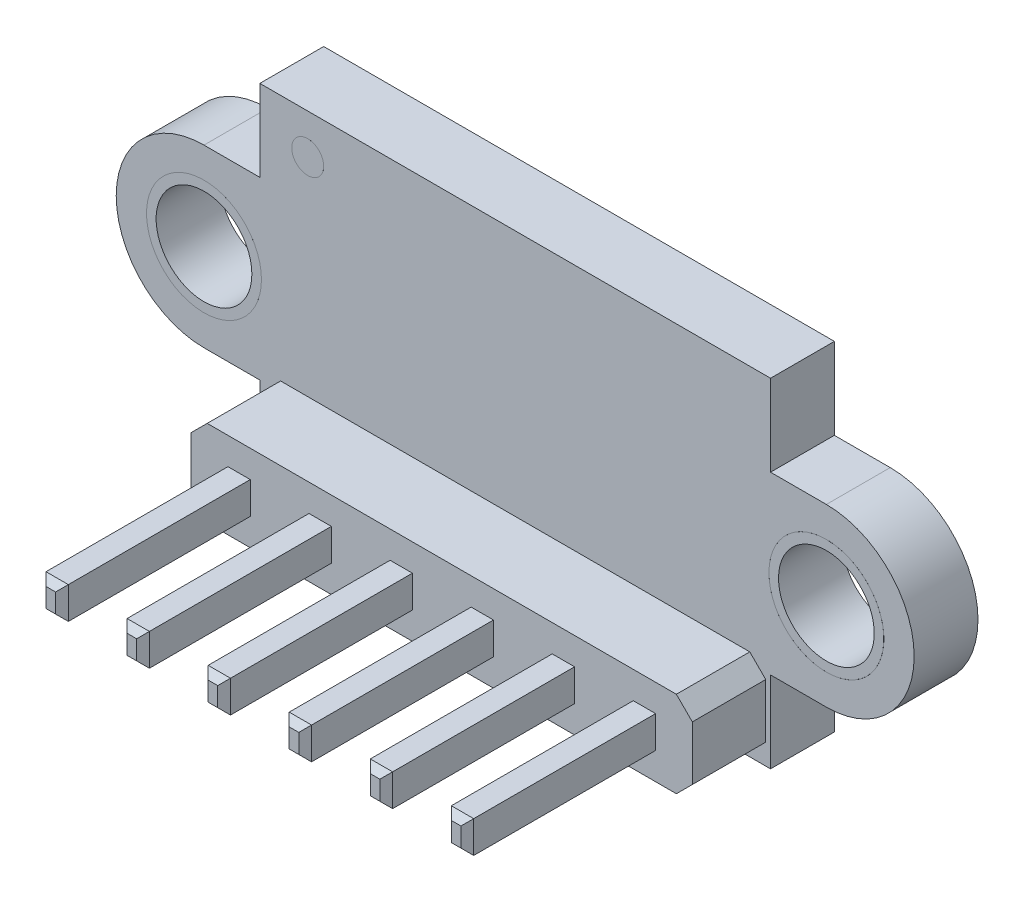
from build123d import *

# Parameters (mm, degrees)
SKETCH1_W                = 16
SKETCH1_H                = 10.6
BOSS_EXTRUDE1_DEPTH      = 1
SKETCH2_R                = 1.5
BOSS_EXTRUDE2_DEPTH      = 1
SKETCH9_R                = 1.8
SKETCH9_R_2              = 1.5
SKETCH9_R_3              = 0.5
BOSS_EXTRUDE9_DEPTH      = 0.0001
SKETCH3_W                = 15.7
SKETCH3_H                = 2.7
BOSS_EXTRUDE3_DEPTH      = 2.3
CHAMFER1_SIZE            = 0.5
SKETCH4_W                = 0.7
SKETCH4_H                = 1
BOSS_EXTRUDE4_DEPTH      = 5.9
BOSS_EXTRUDE4_DEPTH_BACK = 6
CHAMFER3_SIZE            = 0.4
CHAMFER2_SIZE            = 0.2
SKETCH6_W                = 4.4
SKETCH6_H                = 2.4
BOSS_EXTRUDE6_DEPTH      = 1.2
SKETCH8_R                = 0.15
SKETCH8_R_2              = 0.05
CUT_EXTRUDE1_DEPTH       = 0.01
SKETCH5_W                = 4.8
SKETCH5_H                = 2.8
SKETCH5_W_2              = 4.6
SKETCH5_H_2              = 2.6
INSCRI_ES_DEPTH          = 0.0001


with BuildPart() as part:
    # Sketch1 → Boss-Extrude1 (new body, symmetric)
    with BuildSketch(Plane.XY):
        Rectangle(SKETCH1_W, SKETCH1_H)
    extrude(amount=BOSS_EXTRUDE1_DEPTH, both=True)

    # Sketch2 → Boss-Extrude2 (add, symmetric)
    with BuildSketch(Plane.XY):
        with BuildLine():
            Line((-9.75, 2.75), (-8, 2.75))
            Line((-8, 2.75), (-8, -2.75))
            Line((-8, -2.75), (-9.75, -2.75))
            ThreePointArc((-9.75, -2.75), (-12.5, 0), (-9.75, 2.75))
        make_face()
        with Locations((-9.75, 0)):
            Circle(SKETCH2_R, mode=Mode.SUBTRACT)
        with BuildLine():
            Line((9.75, -2.75), (8, -2.75))
            Line((8, -2.75), (8, 2.75))
            Line((8, 2.75), (9.75, 2.75))
            ThreePointArc((9.75, 2.75), (12.5, 0), (9.75, -2.75))
        make_face()
        with Locations((9.75, 0)):
            Circle(SKETCH2_R, mode=Mode.SUBTRACT)
    extrude(amount=BOSS_EXTRUDE2_DEPTH, both=True)

    # Sketch9 → Boss-Extrude9 (add)
    with BuildSketch(Plane(origin=(0, 0, -1), x_dir=(-1, 0, 0), z_dir=(0, 0, -1))):
        with Locations((-9.75, 0)):
            Circle(SKETCH9_R)
        with Locations((-9.75, 0)):
            Circle(SKETCH9_R_2, mode=Mode.SUBTRACT)
        with Locations((9.75, 0)):
            Circle(SKETCH9_R)
        with Locations((9.75, 0)):
            Circle(SKETCH9_R_2, mode=Mode.SUBTRACT)
        with Locations((6.5, 4.05)):
            Circle(SKETCH9_R_3)
    boss_extrude9 = extrude(amount=BOSS_EXTRUDE9_DEPTH)

    # Mirror4: Boss-Extrude9 across plane
    add(boss_extrude9.mirror(Plane.XY))

    # Sketch3 → Boss-Extrude3 (add)
    with BuildSketch(Plane.XY.offset(1)):
        with Locations((0, -3.8)):
            Rectangle(SKETCH3_W, SKETCH3_H)
    extrude(amount=BOSS_EXTRUDE3_DEPTH)

    # Chamfer1
    chamfer1_edges = [part.edges().sort_by_distance(p)[0] for p in [
        (-7.85, -2.45, 2.15),
        (-7.85, -5.15, 2.15),
        (7.85, -5.15, 2.15),
        (7.85, -2.45, 2.15),
    ]]
    chamfer(chamfer1_edges, length=CHAMFER1_SIZE)

    # Sketch4 → Boss-Extrude4 (add, two sides)
    with BuildSketch(Plane.XY.offset(3.3)) as boss_extrude4_sk:
        with Locations((-3.81, -3.8)):
            Rectangle(SKETCH4_W, SKETCH4_H)
        with Locations((-6.35, -3.8)):
            Rectangle(SKETCH4_W, SKETCH4_H)
        with Locations((-1.27, -3.8)):
            Rectangle(SKETCH4_W, SKETCH4_H)
        with Locations((1.27, -3.8)):
            Rectangle(SKETCH4_W, SKETCH4_H)
        with Locations((3.81, -3.8)):
            Rectangle(SKETCH4_W, SKETCH4_H)
        with Locations((6.35, -3.8)):
            Rectangle(SKETCH4_W, SKETCH4_H)
    extrude(amount=BOSS_EXTRUDE4_DEPTH)
    extrude(boss_extrude4_sk.sketch, amount=-BOSS_EXTRUDE4_DEPTH_BACK)

    # Chamfer3
    chamfer3_edges = [part.edges().sort_by_distance(p)[0] for p in [
        (-6.7, -3.8, -1),
        (-6.35, -3.3, -1),
        (-6, -3.8, -1),
        (-6.35, -4.3, -1),
        (-4.16, -3.8, -1),
        (-3.81, -3.3, -1),
        (-3.46, -3.8, -1),
        (-3.81, -4.3, -1),
        (-1.62, -3.8, -1),
        (-1.27, -3.3, -1),
        (-0.92, -3.8, -1),
        (-1.27, -4.3, -1),
        (0.92, -3.8, -1),
        (1.27, -3.3, -1),
        (1.62, -3.8, -1),
        (1.27, -4.3, -1),
        (3.46, -3.8, -1),
        (3.81, -3.3, -1),
        (4.16, -3.8, -1),
        (3.81, -4.3, -1),
        (6, -3.8, -1),
        (6.35, -3.3, -1),
        (6.7, -3.8, -1),
        (6.35, -4.3, -1),
    ]]
    chamfer(chamfer3_edges, length=CHAMFER3_SIZE)

    # Chamfer2
    chamfer2_edges = [part.edges().sort_by_distance(p)[0] for p in [
        (-6.7, -3.8, -2.7),
        (-6.35, -3.3, -2.7),
        (-6, -3.8, -2.7),
        (-6.35, -4.3, -2.7),
        (-6.7, -3.8, 9.2),
        (-6.35, -4.3, 9.2),
        (-6, -3.8, 9.2),
        (-6.35, -3.3, 9.2),
        (-4.16, -3.8, -2.7),
        (-3.81, -3.3, -2.7),
        (-3.46, -3.8, -2.7),
        (-3.81, -4.3, -2.7),
        (-4.16, -3.8, 9.2),
        (-3.81, -4.3, 9.2),
        (-3.46, -3.8, 9.2),
        (-3.81, -3.3, 9.2),
        (-1.62, -3.8, -2.7),
        (-1.27, -3.3, -2.7),
        (-0.92, -3.8, -2.7),
        (-1.27, -4.3, -2.7),
        (-1.62, -3.8, 9.2),
        (-1.27, -4.3, 9.2),
        (-0.92, -3.8, 9.2),
        (-1.27, -3.3, 9.2),
        (0.92, -3.8, -2.7),
        (1.27, -3.3, -2.7),
        (1.62, -3.8, -2.7),
        (1.27, -4.3, -2.7),
        (0.92, -3.8, 9.2),
        (1.27, -4.3, 9.2),
        (1.62, -3.8, 9.2),
        (1.27, -3.3, 9.2),
        (3.46, -3.8, -2.7),
        (3.81, -3.3, -2.7),
        (4.16, -3.8, -2.7),
        (3.81, -4.3, -2.7),
        (3.46, -3.8, 9.2),
        (3.81, -4.3, 9.2),
        (4.16, -3.8, 9.2),
        (3.81, -3.3, 9.2),
        (6, -3.8, -2.7),
        (6.35, -3.3, -2.7),
        (6.7, -3.8, -2.7),
        (6.35, -4.3, -2.7),
        (6, -3.8, 9.2),
        (6.35, -4.3, 9.2),
        (6.7, -3.8, 9.2),
        (6.35, -3.3, 9.2),
    ]]
    chamfer(chamfer2_edges, length=CHAMFER2_SIZE)

    # Sketch6 → Boss-Extrude6 (add)
    with BuildSketch(Plane(origin=(0, 0, -1), x_dir=(-1, 0, 0), z_dir=(0, 0, -1))):
        with Locations((0, 2.1)):
            Rectangle(SKETCH6_W, SKETCH6_H)
    extrude(amount=BOSS_EXTRUDE6_DEPTH)

    # Sketch8 → Cut-Extrude1 (cut)
    with BuildSketch(Plane(origin=(0, 0, -2.2), x_dir=(-1, 0, 0), z_dir=(0, 0, -1))):
        with Locations((-1.55, 2.1)):
            Circle(SKETCH8_R)
        with Locations((1.65, 2.1)):
            Circle(SKETCH8_R_2)
    extrude(amount=-CUT_EXTRUDE1_DEPTH, mode=Mode.SUBTRACT)

    # Sketch5 → Inscrições (add)
    with BuildSketch(Plane(origin=(0, 0, -1), x_dir=(-1, 0, 0), z_dir=(0, 0, -1))):
        with Locations((0, 2.1)):
            Rectangle(SKETCH5_W, SKETCH5_H)
        with Locations((0, 2.1)):
            Rectangle(SKETCH5_W_2, SKETCH5_H_2, mode=Mode.SUBTRACT)
        Polygon((-3.145569905, 4.655439852), (-3.07345452, 4.655439852), (-2.82345452, 4.064394179), (-2.57345452, 4.655439852), (-2.501339136, 4.655439852), (-2.818646828, 3.905439852), (-2.828262213, 3.905439852), align=None)
        Polygon((-2.366723751, 4.655439852), (-2.299416059, 4.655439852), (-2.299416059, 3.982362929), (-2.01095452, 3.982362929), (-2.01095452, 3.905439852), (-2.366723751, 3.905439852), align=None)
        with BuildLine():
            Line((-1.482108366, 4.655439852), (-1.482108366, 4.578516775))
            Line((-1.482108366, 4.578516775), (-1.73721654, 4.578516775))
            Line((-1.73721654, 4.578516775), (-1.777631203, 4.38125115))
            add(Edge.make_bspline(
                [(-1.777631203, 4.38125115), (-1.769690658, 4.383443351), (-1.754307109, 4.387690394), (-1.731601425, 4.392405916), (-1.710045953, 4.395248511), (-1.696058373, 4.395636649), (-1.689289857, 4.395824467)],
                knots=[0, 0, 0, 0, 2.4708e-05, 4.7867e-05, 6.9521e-05, 8.9823e-05, 8.9823e-05, 8.9823e-05, 8.9823e-05], degree=3))
            add(Edge.make_bspline(
                [(-1.689289857, 4.395824467), (-1.68091477, 4.395643195), (-1.664447256, 4.395286769), (-1.640353196, 4.39186423), (-1.61735329, 4.386477106), (-1.59549564, 4.37895128), (-1.574739807, 4.369327765), (-1.555276758, 4.35730635), (-1.536814348, 4.343263493), (-1.519683793, 4.327118133), (-1.504142869, 4.309349215), (-1.490478729, 4.290243957), (-1.478872459, 4.26998803), (-1.469538012, 4.248387899), (-1.462084226, 4.225682366), (-1.457123084, 4.201632527), (-1.453819504, 4.176465073), (-1.453450421, 4.159256951), (-1.453262213, 4.150481919)],
                knots=[0, 0, 0, 0, 2.5112e-05, 4.9377e-05, 7.2845e-05, 9.5889e-05, 0.000118607, 0.000141333, 0.000164381, 0.000188083, 0.000211827, 0.000235091, 0.000258441, 0.00028172, 0.000305571, 0.000329999, 0.000355287, 0.0003816, 0.0003816, 0.0003816, 0.0003816], degree=3))
            add(Edge.make_bspline(
                [(-1.453262213, 4.150481919), (-1.453404729, 4.144370015), (-1.453687835, 4.132228803), (-1.455127532, 4.114197903), (-1.457899472, 4.096548725), (-1.461621127, 4.079278926), (-1.466451645, 4.062421204), (-1.472299299, 4.045927305), (-1.479455591, 4.029899889), (-1.487305171, 4.014187304), (-1.496143702, 3.999144767), (-1.505953382, 3.985077127), (-1.516317416, 3.971773353), (-1.527469142, 3.959376124), (-1.539512212, 3.947966906), (-1.552300776, 3.937477989), (-1.565732788, 3.927731989), (-1.580016054, 3.919124519), (-1.5948323, 3.911203885), (-1.61039549, 3.904705985), (-1.626351354, 3.898896586), (-1.642929542, 3.894265973), (-1.660092501, 3.890637568), (-1.677868525, 3.888173154), (-1.696164383, 3.886378203), (-1.708566171, 3.886265841), (-1.714830722, 3.886209083)],
                knots=[0, 0, 0, 0, 1.8339e-05, 3.6431e-05, 5.4215e-05, 7.1897e-05, 8.9397e-05, 0.00010679, 0.000124348, 0.000142019, 0.000159463, 0.000176633, 0.000193434, 0.000210029, 0.000226607, 0.00024315, 0.00025962, 0.000276343, 0.000293143, 0.000309971, 0.000326889, 0.000344059, 0.000361562, 0.000379473, 0.000397877, 0.000416662, 0.000416662, 0.000416662, 0.000416662], degree=3))
            add(Edge.make_bspline(
                [(-1.714830722, 3.886209083), (-1.722303761, 3.886357119), (-1.737006082, 3.886648364), (-1.758546203, 3.889695182), (-1.779270762, 3.894058879), (-1.799012926, 3.900623794), (-1.817949626, 3.908849643), (-1.835825922, 3.919245965), (-1.853098589, 3.931027202), (-1.869065454, 3.944930134), (-1.883884621, 3.960126352), (-1.897150301, 3.976617275), (-1.908964639, 3.994130727), (-1.919138442, 4.01275176), (-1.927816589, 4.032431445), (-1.934634087, 4.053243517), (-1.940136592, 4.075079232), (-1.942464467, 4.090112127), (-1.943646828, 4.097747544)],
                knots=[0, 0, 0, 0, 2.2404e-05, 4.4077e-05, 6.5148e-05, 8.5862e-05, 0.00010638, 0.000126972, 0.00014781, 0.000169011, 0.000190366, 0.000211414, 0.000232415, 0.000253662, 0.000274988, 0.000296843, 0.000319289, 0.000342457, 0.000342457, 0.000342457, 0.000342457], degree=3))
            Line((-1.943646828, 4.097747544), (-1.876339136, 4.097747544))
            add(Edge.make_bspline(
                [(-1.876339136, 4.097747544), (-1.874683016, 4.090595447), (-1.871499863, 4.07684872), (-1.864512917, 4.057534861), (-1.855970229, 4.040323599), (-1.845812154, 4.024987259), (-1.833694291, 4.011613903), (-1.819866556, 3.999695961), (-1.804363472, 3.988944148), (-1.787136352, 3.979982126), (-1.76896212, 3.972338822), (-1.749940575, 3.967249173), (-1.730589644, 3.96367041), (-1.717501422, 3.963312176), (-1.710924472, 3.96313216)],
                knots=[0, 0, 0, 0, 2.2009e-05, 4.2303e-05, 6.1452e-05, 7.9536e-05, 9.7303e-05, 0.000115408, 0.000134203, 0.000153761, 0.00017357, 0.000193217, 0.00021273, 0.00023244, 0.00023244, 0.00023244, 0.00023244], degree=3))
            add(Edge.make_bspline(
                [(-1.710924472, 3.96313216), (-1.704504806, 3.963308041), (-1.691864429, 3.963654352), (-1.673261989, 3.966319854), (-1.655302088, 3.970425048), (-1.63816194, 3.976568588), (-1.62154161, 3.984035314), (-1.605861516, 3.993617116), (-1.590668043, 4.004644263), (-1.576433443, 4.017277826), (-1.563396418, 4.031199904), (-1.551877249, 4.046087916), (-1.542282196, 4.061970098), (-1.534196316, 4.078571488), (-1.528056323, 4.096074036), (-1.523676113, 4.114395716), (-1.521104029, 4.133581783), (-1.520750204, 4.146668064), (-1.520569905, 4.153336487)],
                knots=[0, 0, 0, 0, 1.9252e-05, 3.7907e-05, 5.6274e-05, 7.4425e-05, 9.2442e-05, 0.000110839, 0.00012944, 0.000148704, 0.000167838, 0.000186589, 0.000205063, 0.000223408, 0.000241893, 0.000260587, 0.000279837, 0.00029984, 0.00029984, 0.00029984, 0.00029984], degree=3))
            add(Edge.make_bspline(
                [(-1.520569905, 4.153336487), (-1.520711008, 4.159352719), (-1.520987196, 4.171128638), (-1.523243747, 4.188357039), (-1.527168812, 4.204658406), (-1.532616787, 4.220111456), (-1.539533824, 4.234730765), (-1.547986605, 4.248531421), (-1.558133762, 4.261331528), (-1.569724881, 4.273137075), (-1.582423033, 4.284032405), (-1.596446692, 4.293320424), (-1.61150239, 4.30113412), (-1.627408733, 4.307877263), (-1.644544069, 4.31272028), (-1.662569061, 4.316356255), (-1.681678356, 4.318459547), (-1.694743503, 4.318751381), (-1.701459328, 4.31890139)],
                knots=[0, 0, 0, 0, 1.8044e-05, 3.532e-05, 5.2009e-05, 6.826e-05, 8.4389e-05, 0.000100442, 0.000116703, 0.000133277, 0.000150013, 0.000166806, 0.000183607, 0.00020085, 0.000218536, 0.000236922, 0.000255969, 0.000276115, 0.000276115, 0.000276115, 0.000276115], degree=3))
            add(Edge.make_bspline(
                [(-1.701459328, 4.31890139), (-1.70727267, 4.318776978), (-1.719275746, 4.318520098), (-1.73768778, 4.316628706), (-1.757036007, 4.313577428), (-1.777246256, 4.309380375), (-1.798379222, 4.303888002), (-1.820390308, 4.297306323), (-1.843325793, 4.289437323), (-1.858779591, 4.283494706), (-1.866723751, 4.280439852)],
                knots=[0, 0, 0, 0, 1.7438e-05, 3.6006e-05, 5.547e-05, 7.6184e-05, 9.7902e-05, 0.000120955, 0.000145091, 0.000170624, 0.000170624, 0.000170624, 0.000170624], degree=3))
            Line((-1.866723751, 4.280439852), (-1.789800674, 4.655439852))
            Line((-1.789800674, 4.655439852), (-1.482108366, 4.655439852))
        make_face()
        with BuildLine():
            Line((-1.28018529, 4.482362929), (-1.347492982, 4.482362929))
            add(Edge.make_bspline(
                [(-1.347492982, 4.482362929), (-1.345669507, 4.489912747), (-1.342104762, 4.504672023), (-1.334669568, 4.525759294), (-1.326569727, 4.545714334), (-1.316843491, 4.564163493), (-1.306234472, 4.581477543), (-1.294079603, 4.597263784), (-1.280939662, 4.611923705), (-1.266405745, 4.624933685), (-1.251163889, 4.636714627), (-1.234999327, 4.646759282), (-1.218237279, 4.655400172), (-1.200761607, 4.662518793), (-1.182520285, 4.667881405), (-1.163678223, 4.671772149), (-1.144186044, 4.674298817), (-1.130954417, 4.674545409), (-1.12423577, 4.674670621)],
                knots=[0, 0, 0, 0, 2.3285e-05, 4.5521e-05, 6.7005e-05, 8.7837e-05, 0.000108014, 0.000127847, 0.000147524, 0.000166988, 0.00018628, 0.000205247, 0.000223994, 0.000242798, 0.000261765, 0.000280947, 0.000300476, 0.000320623, 0.000320623, 0.000320623, 0.000320623], degree=3))
            add(Edge.make_bspline(
                [(-1.12423577, 4.674670621), (-1.114446611, 4.674375072), (-1.095081823, 4.67379042), (-1.066632599, 4.668451612), (-1.03919828, 4.660003369), (-1.013079156, 4.648330428), (-0.988818063, 4.633933147), (-0.967231738, 4.616797846), (-0.948612771, 4.597255138), (-0.932992547, 4.575669589), (-0.92076219, 4.552600551), (-0.911743682, 4.52885766), (-0.906253321, 4.504497238), (-0.905541774, 4.488049249), (-0.90518529, 4.479808842)],
                knots=[0, 0, 0, 0, 2.9343e-05, 5.8047e-05, 8.6512e-05, 0.000115298, 0.000143666, 0.000170931, 0.00019771, 0.000224397, 0.000250609, 0.000275808, 0.000300415, 0.00032512, 0.00032512, 0.00032512, 0.00032512], degree=3))
            add(Edge.make_bspline(
                [(-0.90518529, 4.479808842), (-0.90543463, 4.471878815), (-0.905922552, 4.456360982), (-0.910065489, 4.433706375), (-0.917037545, 4.412354604), (-0.926695351, 4.392215783), (-0.939197112, 4.373417603), (-0.954341262, 4.35591777), (-0.972234689, 4.339638664), (-0.985794462, 4.330313063), (-0.992775434, 4.325511967)],
                knots=[0, 0, 0, 0, 2.3776e-05, 4.6527e-05, 6.881e-05, 9.0985e-05, 0.00011332, 0.000136329, 0.000160261, 0.000185656, 0.000185656, 0.000185656, 0.000185656], degree=3))
            add(Edge.make_bspline(
                [(-0.992775434, 4.325511967), (-0.984797201, 4.321659502), (-0.968990013, 4.314026654), (-0.947443471, 4.299057563), (-0.927883927, 4.28177406), (-0.916975987, 4.268286349), (-0.911495386, 4.261509563)],
                knots=[0, 0, 0, 0, 2.6542e-05, 5.2587e-05, 7.844e-05, 0.000104546, 0.000104546, 0.000104546, 0.000104546], degree=3))
            add(Edge.make_bspline(
                [(-0.911495386, 4.261509563), (-0.907886527, 4.256568617), (-0.900727906, 4.246767635), (-0.89189172, 4.231009829), (-0.883875481, 4.215077367), (-0.877629006, 4.198543209), (-0.872791749, 4.181598991), (-0.869334027, 4.164215621), (-0.867185997, 4.146378902), (-0.866878379, 4.134311942), (-0.866723751, 4.128246342)],
                knots=[0, 0, 0, 0, 1.8339e-05, 3.6378e-05, 5.4117e-05, 7.1807e-05, 8.9307e-05, 0.000106927, 0.000124929, 0.000143123, 0.000143123, 0.000143123, 0.000143123], degree=3))
            add(Edge.make_bspline(
                [(-0.866723751, 4.128246342), (-0.86710829, 4.117744259), (-0.867875557, 4.096789516), (-0.874733573, 4.065830647), (-0.885364982, 4.035568039), (-0.900462897, 4.006623431), (-0.918863077, 3.979541921), (-0.940753932, 3.955311283), (-0.965886734, 3.934483011), (-0.993916516, 3.917080819), (-1.024284472, 3.903169836), (-1.056764956, 3.893514669), (-1.090889968, 3.887226241), (-1.114291532, 3.886551912), (-1.126188895, 3.886209083)],
                knots=[0, 0, 0, 0, 3.1471e-05, 6.2793e-05, 9.4678e-05, 0.000127469, 0.000160432, 0.000192661, 0.000225094, 0.000258028, 0.000291376, 0.000324977, 0.000359459, 0.00039512, 0.00039512, 0.00039512, 0.00039512], degree=3))
            add(Edge.make_bspline(
                [(-1.126188895, 3.886209083), (-1.134207317, 3.886395128), (-1.149984896, 3.886761204), (-1.173179932, 3.889263762), (-1.195320296, 3.893834477), (-1.216435924, 3.899985185), (-1.236545575, 3.907783416), (-1.255587883, 3.917494565), (-1.273680003, 3.928918459), (-1.290651207, 3.942189942), (-1.306499471, 3.957035943), (-1.320803627, 3.973720017), (-1.333802154, 3.991933746), (-1.345147005, 4.011888687), (-1.355354923, 4.033326956), (-1.363750842, 4.056523063), (-1.371140607, 4.081269639), (-1.37457635, 4.098514869), (-1.376339136, 4.107362929)],
                knots=[0, 0, 0, 0, 2.4055e-05, 4.7333e-05, 6.9873e-05, 9.1791e-05, 0.000113246, 0.000134478, 0.000155818, 0.000177336, 0.000199018, 0.000220854, 0.000243157, 0.000266041, 0.000289631, 0.000314302, 0.000339975, 0.000367027, 0.000367027, 0.000367027, 0.000367027], degree=3))
            Line((-1.376339136, 4.107362929), (-1.309031443, 4.107362929))
            add(Edge.make_bspline(
                [(-1.309031443, 4.107362929), (-1.307277881, 4.10158814), (-1.30386705, 4.090355675), (-1.298061129, 4.074189895), (-1.291446499, 4.059370312), (-1.284350522, 4.045788215), (-1.276897998, 4.033309843), (-1.268559085, 4.022265157), (-1.259951411, 4.012169042), (-1.253462979, 4.006480911), (-1.250287453, 4.003697063)],
                knots=[0, 0, 0, 0, 1.8104e-05, 3.5215e-05, 5.1491e-05, 6.6746e-05, 8.1175e-05, 9.5027e-05, 0.000108228, 0.000120881, 0.000120881, 0.000120881, 0.000120881], degree=3))
            add(Edge.make_bspline(
                [(-1.250287453, 4.003697063), (-1.246088187, 4.000459563), (-1.237702616, 3.993994557), (-1.224037995, 3.985744208), (-1.209666948, 3.978595416), (-1.194278089, 3.973134624), (-1.178203496, 3.96851084), (-1.161183346, 3.965485014), (-1.143367799, 3.963408978), (-1.131203279, 3.963225778), (-1.124986972, 3.96313216)],
                knots=[0, 0, 0, 0, 1.5896e-05, 3.1742e-05, 4.7801e-05, 6.3962e-05, 8.0657e-05, 9.7925e-05, 0.000115761, 0.0001344, 0.0001344, 0.0001344, 0.0001344], degree=3))
            add(Edge.make_bspline(
                [(-1.124986972, 3.96313216), (-1.117968365, 3.963264139), (-1.104244083, 3.963522214), (-1.084218042, 3.96589558), (-1.065166446, 3.969352097), (-1.047300819, 3.974690593), (-1.030387139, 3.98128649), (-1.0146625, 3.989568291), (-0.999920477, 3.999285017), (-0.98634989, 4.010329123), (-0.974147281, 4.022419443), (-0.9634031, 4.035065101), (-0.954269244, 4.048212779), (-0.946901334, 4.061935234), (-0.941083359, 4.07617564), (-0.937122673, 4.09097396), (-0.934368777, 4.106209089), (-0.934144503, 4.116565296), (-0.934031443, 4.121786006)],
                knots=[0, 0, 0, 0, 2.1047e-05, 4.1156e-05, 6.0426e-05, 7.9062e-05, 9.7001e-05, 0.00011481, 0.000132269, 0.000149891, 0.000167208, 0.000183732, 0.00019961, 0.000215138, 0.000230371, 0.000245643, 0.000261031, 0.000276674, 0.000276674, 0.000276674, 0.000276674], degree=3))
            add(Edge.make_bspline(
                [(-0.934031443, 4.121786006), (-0.934359365, 4.12877415), (-0.935013577, 4.142715666), (-0.940008273, 4.163226575), (-0.948223743, 4.182988734), (-0.959724996, 4.201664975), (-0.973725509, 4.218974097), (-0.990089418, 4.234417986), (-1.00895261, 4.247161577), (-1.02631401, 4.255966289), (-1.041692258, 4.261974234), (-1.054852697, 4.265976012), (-1.069586255, 4.269364652), (-1.085714759, 4.272517282), (-1.103359734, 4.275200428), (-1.12250197, 4.27743796), (-1.143145348, 4.279228326), (-1.157436312, 4.280027846), (-1.164800674, 4.280439852)],
                knots=[0, 0, 0, 0, 2.0949e-05, 4.1793e-05, 6.2942e-05, 8.4921e-05, 0.000107353, 0.000129569, 0.000152155, 0.000175403, 0.000187819, 0.000201648, 0.000216626, 0.000233155, 0.00025094, 0.000270153, 0.000290965, 0.000313092, 0.000313092, 0.000313092, 0.000313092], degree=3))
            Line((-1.164800674, 4.280439852), (-1.164800674, 4.357362929))
            add(Edge.make_bspline(
                [(-1.164800674, 4.357362929), (-1.155521853, 4.357520387), (-1.137346922, 4.357828808), (-1.110798142, 4.361559096), (-1.085411004, 4.366719231), (-1.06174813, 4.3746232), (-1.040180549, 4.383803264), (-1.021469206, 4.39448588), (-1.005876245, 4.40636047), (-0.993477444, 4.419610314), (-0.984149753, 4.433820682), (-0.977329725, 4.448631394), (-0.973301083, 4.464172264), (-0.972763297, 4.474778265), (-0.972492982, 4.480109323)],
                knots=[0, 0, 0, 0, 2.7814e-05, 5.4481e-05, 8.0295e-05, 0.000105428, 0.00012918, 0.000150518, 0.000169901, 0.00018776, 0.000204678, 0.000220681, 0.000236495, 0.000252478, 0.000252478, 0.000252478, 0.000252478], degree=3))
            add(Edge.make_bspline(
                [(-0.972492982, 4.480109323), (-0.972581784, 4.484025983), (-0.972758452, 4.491817991), (-0.97498644, 4.503201935), (-0.978334449, 4.514237852), (-0.982937248, 4.524878811), (-0.989098005, 4.535051013), (-0.996470717, 4.54484118), (-1.005249595, 4.554193419), (-1.015309334, 4.56291063), (-1.026111863, 4.571218324), (-1.037951101, 4.578271246), (-1.050470074, 4.584302331), (-1.063682643, 4.589275795), (-1.077631685, 4.593017071), (-1.092251662, 4.595703323), (-1.107570451, 4.59738282), (-1.118021537, 4.597624624), (-1.123334328, 4.597747544)],
                knots=[0, 0, 0, 0, 1.1734e-05, 2.3345e-05, 3.4656e-05, 4.6295e-05, 5.8019e-05, 7.0248e-05, 8.3004e-05, 9.6416e-05, 0.000110148, 0.00012383, 0.000137673, 0.000151793, 0.000166116, 0.000180938, 0.000196352, 0.000212288, 0.000212288, 0.000212288, 0.000212288], degree=3))
            add(Edge.make_bspline(
                [(-1.123334328, 4.597747544), (-1.131873971, 4.597449395), (-1.14855388, 4.596867041), (-1.172599934, 4.591766395), (-1.194954077, 4.583628234), (-1.212040934, 4.573914016), (-1.224658629, 4.564324637), (-1.233675115, 4.55594984), (-1.24252951, 4.546642807), (-1.250639298, 4.535830298), (-1.258840865, 4.524244557), (-1.266307557, 4.511296625), (-1.273563205, 4.497324255), (-1.27793518, 4.487446619), (-1.28018529, 4.482362929)],
                knots=[0, 0, 0, 0, 2.5594e-05, 4.9992e-05, 7.3379e-05, 9.6729e-05, 0.000108628, 0.000120857, 0.000133612, 0.000147105, 0.000161358, 0.000176174, 0.000191898, 0.000208572, 0.000208572, 0.000208572, 0.000208572], degree=3))
        make_face()
        Polygon((-0.732108366, 4.655439852), (-0.664800674, 4.655439852), (-0.664800674, 3.982362929), (-0.376339136, 3.982362929), (-0.376339136, 3.905439852), (-0.732108366, 3.905439852), align=None)
        with BuildLine():
            add(Edge.make_bspline(
                [(-0.318646828, 4.280139371), (-0.318576538, 4.29216024), (-0.31844, 4.315510951), (-0.316921052, 4.349536231), (-0.314397765, 4.381456293), (-0.310939756, 4.411272665), (-0.306731618, 4.438993043), (-0.301114013, 4.464543348), (-0.294725556, 4.488041835), (-0.28732146, 4.509565131), (-0.278966934, 4.52940321), (-0.269873878, 4.547922896), (-0.259681422, 4.565096167), (-0.248972084, 4.581197122), (-0.237312354, 4.5959622), (-0.225034042, 4.609599913), (-0.211657926, 4.621795074), (-0.197638709, 4.632904996), (-0.182849467, 4.642644169), (-0.167711753, 4.651222613), (-0.152121373, 4.658551156), (-0.136035762, 4.664313392), (-0.1195995, 4.669072859), (-0.102755129, 4.672327633), (-0.085474836, 4.674375542), (-0.073810957, 4.674571328), (-0.067895626, 4.674670621)],
                knots=[0, 0, 0, 0, 3.6061e-05, 7.0048e-05, 0.000102151, 0.000132099, 0.000160084, 0.000186223, 0.000210534, 0.000233103, 0.000254449, 0.000275076, 0.000294943, 0.000314319, 0.000333044, 0.000351336, 0.000369305, 0.000387279, 0.000404947, 0.000422371, 0.000439443, 0.000456554, 0.000473579, 0.000490728, 0.000507966, 0.000525705, 0.000525705, 0.000525705, 0.000525705], degree=3))
            add(Edge.make_bspline(
                [(-0.067895626, 4.674670621), (-0.061930881, 4.674566089), (-0.050068879, 4.674358208), (-0.032531656, 4.672360221), (-0.015399581, 4.66904498), (0.001254306, 4.664347628), (0.017566803, 4.658519983), (0.033410319, 4.651215601), (0.048883265, 4.642712987), (0.063739755, 4.632722156), (0.078142887, 4.621583097), (0.091738879, 4.608991096), (0.104528969, 4.595073299), (0.116673677, 4.579978614), (0.127828448, 4.563417524), (0.138451327, 4.545678072), (0.14795962, 4.52645003), (0.15711705, 4.506054215), (0.165021405, 4.483926289), (0.172149886, 4.460190983), (0.177909665, 4.434567943), (0.182707366, 4.407191604), (0.186424129, 4.377961429), (0.189131124, 4.346940076), (0.190561071, 4.314107135), (0.190830364, 4.291659025), (0.190968557, 4.280139371)],
                knots=[0, 0, 0, 0, 1.7889e-05, 3.5575e-05, 5.2871e-05, 7.0186e-05, 8.7437e-05, 0.000104783, 0.000122469, 0.000140345, 0.000158437, 0.000177043, 0.000195862, 0.000215102, 0.000235104, 0.000255717, 0.000277084, 0.000299416, 0.000322752, 0.000347518, 0.000373722, 0.000401486, 0.000430873, 0.00046209, 0.000494877, 0.000529438, 0.000529438, 0.000529438, 0.000529438], degree=3))
            add(Edge.make_bspline(
                [(0.190968557, 4.280139371), (0.190828931, 4.268669962), (0.190556877, 4.246322287), (0.189147154, 4.213637078), (0.186370305, 4.182780354), (0.182896736, 4.153678112), (0.178085815, 4.12645148), (0.172170422, 4.101006241), (0.165602496, 4.077232511), (0.15749504, 4.055325052), (0.148621317, 4.034978254), (0.138966632, 4.015978151), (0.128623098, 3.998156802), (0.117354081, 3.981656856), (0.105342635, 3.96636143), (0.09233168, 3.952540511), (0.078687984, 3.939861081), (0.064242466, 3.928578589), (0.049154276, 3.918703274), (0.033734474, 3.909871735), (0.017709463, 3.902750443), (0.001442402, 3.896635791), (-0.015299391, 3.891964266), (-0.032495046, 3.888734154), (-0.050057096, 3.886468758), (-0.06192886, 3.886295941), (-0.067895626, 3.886209083)],
                knots=[0, 0, 0, 0, 3.441e-05, 6.7047e-05, 9.8115e-05, 0.000127334, 0.000154949, 0.000181007, 0.000205689, 0.000228884, 0.000251019, 0.000272251, 0.000292788, 0.00031279, 0.000332148, 0.000351069, 0.000369675, 0.000387978, 0.000405979, 0.000423738, 0.000441221, 0.000458524, 0.000475839, 0.000493282, 0.000510986, 0.000528874, 0.000528874, 0.000528874, 0.000528874], degree=3))
            add(Edge.make_bspline(
                [(-0.067895626, 3.886209083), (-0.073810793, 3.886309016), (-0.085474349, 3.886506065), (-0.102757011, 3.888544722), (-0.119531821, 3.89182233), (-0.135881554, 3.896411602), (-0.151890093, 3.902029067), (-0.167339297, 3.909347713), (-0.182400943, 3.917776442), (-0.197034848, 3.927375461), (-0.210966026, 3.938372965), (-0.22427287, 3.950536741), (-0.236621088, 3.964170329), (-0.248114108, 3.979058455), (-0.259037127, 3.99506415), (-0.26908485, 4.012405944), (-0.278378605, 4.031015075), (-0.286873638, 4.05101177), (-0.294405495, 4.072687826), (-0.301058575, 4.096291222), (-0.306311609, 4.122030287), (-0.310807956, 4.149698294), (-0.31443461, 4.179414136), (-0.316910537, 4.211193946), (-0.318440819, 4.245017919), (-0.318576905, 4.268218585), (-0.318646828, 4.280139371)],
                knots=[0, 0, 0, 0, 1.7739e-05, 3.4977e-05, 5.2125e-05, 6.8966e-05, 8.5884e-05, 0.000102956, 0.000120176, 0.000137635, 0.000155398, 0.000173367, 0.00019166, 0.000210503, 0.000229755, 0.000249751, 0.000270579, 0.000292122, 0.000314882, 0.000339378, 0.000365633, 0.000393642, 0.000423458, 0.000455411, 0.000489249, 0.000525009, 0.000525009, 0.000525009, 0.000525009], degree=3))
        make_face()
        with BuildLine():
            add(Edge.make_bspline(
                [(-0.251339136, 4.280439852), (-0.25131354, 4.270422274), (-0.251263863, 4.250980121), (-0.249966106, 4.222727994), (-0.248198199, 4.196377209), (-0.245917921, 4.171894308), (-0.242531575, 4.149362163), (-0.238737264, 4.128625802), (-0.234119816, 4.109794966), (-0.228656598, 4.092740435), (-0.222433934, 4.077172777), (-0.21563982, 4.062686803), (-0.208341094, 4.049111388), (-0.200172705, 4.036568472), (-0.19127662, 4.025017151), (-0.181853778, 4.014252972), (-0.17155251, 4.004653619), (-0.157301708, 3.993140722), (-0.138488178, 3.981243764), (-0.114783795, 3.970883888), (-0.09042627, 3.964373362), (-0.073893859, 3.963545414), (-0.06564202, 3.96313216)],
                knots=[0, 0, 0, 0, 3.005e-05, 5.832e-05, 8.4824e-05, 0.000109281, 0.000132059, 0.000153156, 0.000172505, 0.00019018, 0.000206836, 0.000222765, 0.000238161, 0.000253038, 0.000267612, 0.000281873, 0.000295902, 0.000309793, 0.000336803, 0.00036237, 0.000387185, 0.000411914, 0.000411914, 0.000411914, 0.000411914], degree=3))
            add(Edge.make_bspline(
                [(-0.06564202, 3.96313216), (-0.057336805, 3.963474541), (-0.040743521, 3.964158598), (-0.016500565, 3.970758327), (0.007034493, 3.980716085), (0.02547848, 3.992490551), (0.039510453, 4.003703764), (0.049564094, 4.013264046), (0.058791676, 4.023968875), (0.067543549, 4.035518724), (0.075570494, 4.048134256), (0.082869738, 4.061754808), (0.089530455, 4.076418203), (0.093325251, 4.086654576), (0.095265432, 4.091888169)],
                knots=[0, 0, 0, 0, 2.4866e-05, 4.9682e-05, 7.4854e-05, 0.000101322, 0.000115002, 0.00012871, 0.000142871, 0.000157355, 0.00017215, 0.000187678, 0.000203681, 0.000220421, 0.000220421, 0.000220421, 0.000220421], degree=3))
            add(Edge.make_bspline(
                [(0.095265432, 4.091888169), (0.097526525, 4.098580256), (0.102117513, 4.112168063), (0.108034322, 4.133245988), (0.112694051, 4.155360866), (0.1168862, 4.178380534), (0.119747569, 4.202474756), (0.122050672, 4.227568981), (0.123407248, 4.25368213), (0.123575409, 4.271423914), (0.123660864, 4.280439852)],
                knots=[0, 0, 0, 0, 2.119e-05, 4.3024e-05, 6.5627e-05, 8.8969e-05, 0.000113194, 0.000138385, 0.000164562, 0.000191609, 0.000191609, 0.000191609, 0.000191609], degree=3))
            add(Edge.make_bspline(
                [(0.123660864, 4.280439852), (0.123542967, 4.289454332), (0.123312334, 4.307088581), (0.122430765, 4.332913906), (0.120154284, 4.357442712), (0.117625902, 4.38078067), (0.113897926, 4.402798592), (0.109878396, 4.4236808), (0.104478136, 4.443168591), (0.098709613, 4.461567073), (0.092107385, 4.478667213), (0.084839728, 4.494548739), (0.077077922, 4.509288323), (0.068647442, 4.522845525), (0.059648367, 4.53528107), (0.049843178, 4.546345626), (0.039620813, 4.556382119), (0.025302844, 4.567838384), (0.006558354, 4.579519461), (-0.016765714, 4.590269267), (-0.041037995, 4.596442472), (-0.057446592, 4.597312834), (-0.06564202, 4.597747544)],
                knots=[0, 0, 0, 0, 2.7047e-05, 5.291e-05, 7.7489e-05, 0.000100933, 0.000123311, 0.000144466, 0.000164693, 0.000183936, 0.000202295, 0.00021964, 0.000236308, 0.000252234, 0.000267499, 0.000282297, 0.000296534, 0.000310425, 0.000337227, 0.000362581, 0.000387213, 0.000411793, 0.000411793, 0.000411793, 0.000411793], degree=3))
            add(Edge.make_bspline(
                [(-0.06564202, 4.597747544), (-0.073937147, 4.597312234), (-0.090542513, 4.596440821), (-0.115067074, 4.590292267), (-0.13857515, 4.579575203), (-0.157270073, 4.567799694), (-0.171598027, 4.556584342), (-0.181687176, 4.546858673), (-0.19114707, 4.53622019), (-0.199861577, 4.524562637), (-0.208023566, 4.512034344), (-0.215519497, 4.498536751), (-0.222273211, 4.484001459), (-0.228505612, 4.468440794), (-0.233985495, 4.451387735), (-0.23850563, 4.432580093), (-0.242681427, 4.411909688), (-0.245637556, 4.389255508), (-0.248265504, 4.364766475), (-0.249954364, 4.338349907), (-0.251268205, 4.310050397), (-0.251315018, 4.29050772), (-0.251339136, 4.280439852)],
                knots=[0, 0, 0, 0, 2.4879e-05, 4.9803e-05, 7.5293e-05, 0.000102096, 0.000115893, 0.000129813, 0.000144074, 0.000158557, 0.000173434, 0.000188902, 0.000204831, 0.000221487, 0.000239162, 0.000258511, 0.00027949, 0.000302394, 0.000327016, 0.00035337, 0.000381791, 0.000411991, 0.000411991, 0.000411991, 0.000411991], degree=3))
        make_face(mode=Mode.SUBTRACT)
        Polygon((0.652507018, 4.674670621), (0.338805095, 3.799670621), (0.267891634, 3.799670621), (0.581593557, 4.674670621), align=None)
        Polygon((0.869604374, 4.655439852), (1.008276249, 4.655439852), (1.008276249, 3.905439852), (0.940968557, 3.905439852), (0.940968557, 4.578516775), (0.825583941, 4.578516775), align=None)
        Polygon((1.30154548, 4.655439852), (1.379219759, 4.655439852), (1.575583941, 4.348648987), (1.771948124, 4.655439852), (1.849622403, 4.655439852), (1.614496201, 4.287951871), (1.859237787, 3.905439852), (1.781563509, 3.905439852), (1.575583941, 4.227254756), (1.369604374, 3.905439852), (1.291930095, 3.905439852), (1.536821922, 4.287951871), align=None)
        Polygon((1.931353172, 4.655439852), (2.003468557, 4.655439852), (2.253468557, 4.064394179), (2.503468557, 4.655439852), (2.575583941, 4.655439852), (2.258276249, 3.905439852), (2.248660864, 3.905439852), align=None)
        with BuildLine():
            Line((2.73904548, 4.424670621), (2.671737787, 4.424670621))
            add(Edge.make_bspline(
                [(2.671737787, 4.424670621), (2.672176463, 4.433600097), (2.67303801, 4.45113735), (2.677072644, 4.476706759), (2.682845689, 4.501147073), (2.691008143, 4.524262054), (2.701145203, 4.546256084), (2.713301637, 4.567041802), (2.72770032, 4.586539914), (2.744030334, 4.604569666), (2.761766471, 4.62110986), (2.780903458, 4.635393126), (2.801013107, 4.647461199), (2.822034406, 4.657550036), (2.844204527, 4.66512286), (2.867322282, 4.670741783), (2.89148924, 4.674122429), (2.907954959, 4.674485811), (2.916329134, 4.674670621)],
                knots=[0, 0, 0, 0, 2.6803e-05, 5.2641e-05, 7.753e-05, 0.000102048, 0.000126046, 0.000150087, 0.000174156, 0.000198624, 0.00022297, 0.000246799, 0.000270117, 0.000293235, 0.000316612, 0.000340261, 0.000364526, 0.000389638, 0.000389638, 0.000389638, 0.000389638], degree=3))
            add(Edge.make_bspline(
                [(2.916329134, 4.674670621), (2.924553007, 4.674478095), (2.940712623, 4.674099787), (2.964297341, 4.670850995), (2.986749618, 4.665762654), (3.008025568, 4.658623636), (3.027955439, 4.649026973), (3.046688949, 4.637498929), (3.064449122, 4.624166108), (3.08043629, 4.608468863), (3.095116593, 4.591711209), (3.107781362, 4.573820944), (3.11862704, 4.55534324), (3.127667257, 4.536137197), (3.134322144, 4.516021976), (3.139374617, 4.495290433), (3.142230491, 4.473727973), (3.142668796, 4.459133711), (3.142891634, 4.45171389)],
                knots=[0, 0, 0, 0, 2.4662e-05, 4.846e-05, 7.1274e-05, 9.3652e-05, 0.000115627, 0.000137477, 0.000159563, 0.000182089, 0.000204562, 0.000226323, 0.000247736, 0.000268775, 0.00028987, 0.000311188, 0.000332712, 0.000354972, 0.000354972, 0.000354972, 0.000354972], degree=3))
            add(Edge.make_bspline(
                [(3.142891634, 4.45171389), (3.142528792, 4.441267926), (3.141809475, 4.420559309), (3.135656394, 4.390127552), (3.126046427, 4.360643248), (3.114475565, 4.336913826), (3.102802899, 4.317792363), (3.092284147, 4.302049069), (3.079970259, 4.285097898), (3.065682009, 4.266995611), (3.049714965, 4.247600417), (3.031924502, 4.226924032), (3.012183756, 4.205180082), (2.998328363, 4.190328881), (2.991148845, 4.182633362)],
                knots=[0, 0, 0, 0, 3.1311e-05, 6.2072e-05, 9.2764e-05, 0.000124144, 0.000140995, 0.000159955, 0.000180931, 0.000203833, 0.000229129, 0.000256294, 0.000285653, 0.000317227, 0.000317227, 0.000317227, 0.000317227], degree=3))
            Line((2.991148845, 4.182633362), (2.803498605, 3.982362929))
            Line((2.803498605, 3.982362929), (3.152507018, 3.982362929))
            Line((3.152507018, 3.982362929), (3.152507018, 3.905439852))
            Line((3.152507018, 3.905439852), (2.642891634, 3.905439852))
            Line((2.642891634, 3.905439852), (2.933757018, 4.215836487))
            add(Edge.make_bspline(
                [(2.933757018, 4.215836487), (2.940838708, 4.223228981), (2.954441185, 4.237428449), (2.973680309, 4.258159084), (2.990960092, 4.277391128), (3.006392391, 4.295088246), (3.019642428, 4.311509296), (3.031400763, 4.326122447), (3.040821961, 4.339569829), (3.051046689, 4.355157103), (3.060949685, 4.374188314), (3.069459475, 4.397445533), (3.074648371, 4.421387087), (3.075270836, 4.437566095), (3.075583941, 4.445704275)],
                knots=[0, 0, 0, 0, 3.0711e-05, 5.899e-05, 8.4842e-05, 0.000108276, 0.000129418, 0.000148142, 0.000164525, 0.000178652, 0.000204053, 0.000228672, 0.000252775, 0.00027717, 0.00027717, 0.00027717, 0.00027717], degree=3))
            add(Edge.make_bspline(
                [(3.075583941, 4.445704275), (3.075447711, 4.450821718), (3.075179227, 4.460907214), (3.07280972, 4.475694162), (3.069228897, 4.489958051), (3.064097771, 4.503742755), (3.057324898, 4.516909681), (3.049080602, 4.529474855), (3.039568446, 4.54162249), (3.028564602, 4.553012483), (3.016476419, 4.56344417), (3.003706223, 4.572685045), (2.990195486, 4.580407712), (2.976001174, 4.586738461), (2.96116286, 4.591704614), (2.945651843, 4.595145738), (2.929510982, 4.597306271), (2.918489519, 4.597598593), (2.912873605, 4.597747544)],
                knots=[0, 0, 0, 0, 1.5343e-05, 3.0238e-05, 4.4814e-05, 5.9409e-05, 7.4258e-05, 8.9135e-05, 0.000104434, 0.000120478, 0.000136563, 0.000152281, 0.000167692, 0.000183161, 0.000198839, 0.000214548, 0.000230761, 0.000247605, 0.000247605, 0.000247605, 0.000247605], degree=3))
            add(Edge.make_bspline(
                [(2.912873605, 4.597747544), (2.907008426, 4.597594323), (2.895490184, 4.597293422), (2.878578963, 4.595188565), (2.862446296, 4.591557314), (2.847051603, 4.586590884), (2.832368834, 4.580278337), (2.818469396, 4.572415821), (2.805384492, 4.563033644), (2.793089522, 4.552396382), (2.781761527, 4.540553324), (2.771808625, 4.527351189), (2.76311205, 4.513031029), (2.755524357, 4.497631482), (2.749362424, 4.481012815), (2.744653892, 4.463234021), (2.740928139, 4.444372297), (2.739683456, 4.431346921), (2.73904548, 4.424670621)],
                knots=[0, 0, 0, 0, 1.7594e-05, 3.4552e-05, 5.1027e-05, 6.7134e-05, 8.3015e-05, 9.8892e-05, 0.000114942, 0.000131238, 0.000147604, 0.000164011, 0.000180733, 0.0001978, 0.000215437, 0.000233806, 0.000252929, 0.000273037, 0.000273037, 0.000273037, 0.000273037], degree=3))
        make_face()
    extrude(amount=INSCRI_ES_DEPTH)


solid = part.part
